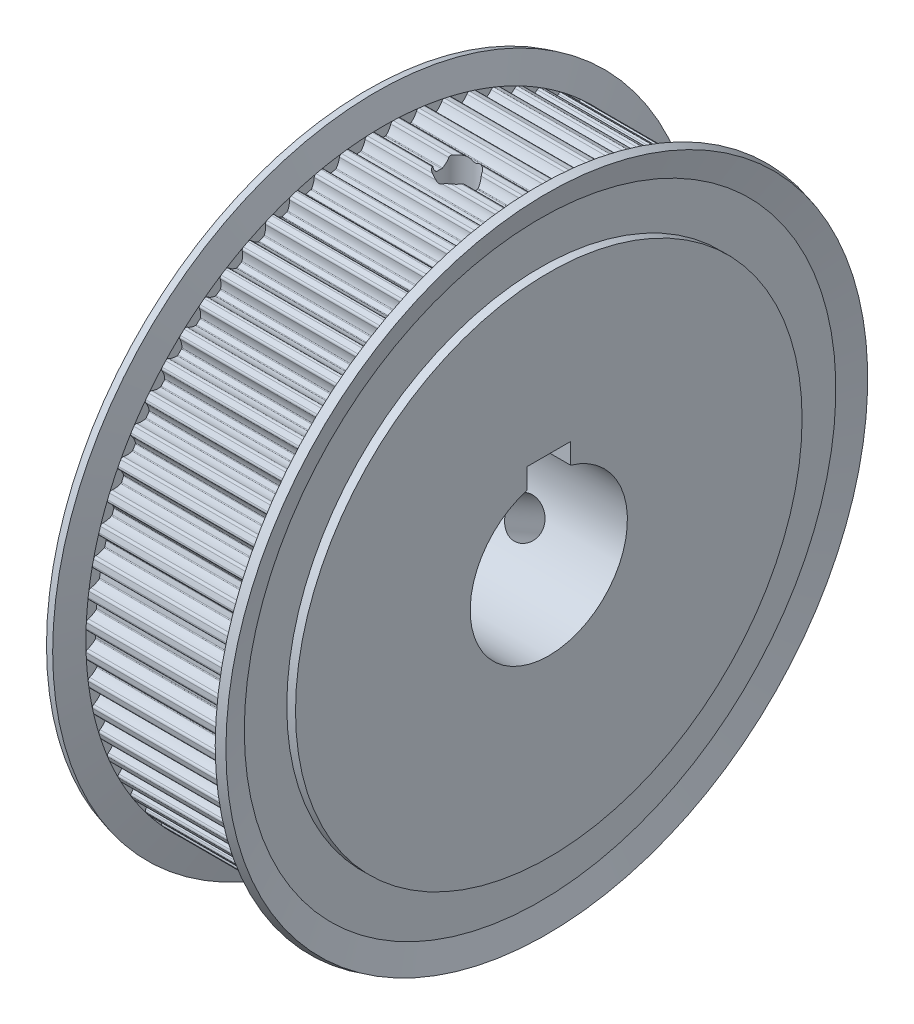
from build123d import *

# Parameters (mm, degrees)
SKETCH_2_W          = 21
SKETCH_2_H          = 9
SKETCH_3_R          = 38.995
CUT_EXTRUDE_1_DEPTH = 17
SKETCH_4_W          = 5
SKETCH_4_H          = 11
CUT_EXTRUDE_2_DEPTH = 21
SKETCH_5_W          = 2.067
SKETCH_5_H          = 33.995


with BuildPart() as part:
    # ｽｹｯﾁ1 → 回転1 (revolve)
    with BuildSketch(Plane.XY):
        Polygon((0, 0), (0, 29), (1, 29), (1, 33.863347502), (0.22888685, 36.741180955), (1.194812677, 37), (2, 33.995), (19, 33.995), (19.805187323, 37), (20.77111315, 36.741180955), (20, 33.863347502), (20, 29), (21, 29), (21, 0), align=None)
    revolve(axis=Axis((21, 0, 0), (-1, 0, 0)))

    # ｽｹｯﾁ2 → ｶｯﾄ - 回転1 (revolve, cut)
    with BuildSketch(Plane.XY):
        with Locations((10.5, 4.5)):
            Rectangle(SKETCH_2_W, SKETCH_2_H)
    revolve(axis=Axis((21, 0, 0), (-1, 0, 0)), mode=Mode.SUBTRACT)

    # ｽｹｯﾁ3 → ｶｯﾄ - 押し出し1 (cut)
    with BuildSketch(Plane(origin=(2, 0, 0), x_dir=(0, 0, -1), z_dir=(1, 0, 0))):
        Circle(SKETCH_3_R)
        with BuildLine():
            ThreePointArc((-33.777168623, -0.911681599), (-33.922614353, -1.016968917), (-33.974202204, -1.18895314))
            ThreePointArc((-33.974202204, -1.18895314), (-33.962644297, -1.482840979), (-33.948544212, -1.776617823))
            ThreePointArc((-33.948544212, -1.776617823), (-33.882163306, -1.943451535), (-33.728094586, -2.035661844))
            ThreePointArc((-33.728094586, -2.035661844), (-33.250950848, -2.205234651), (-32.83260935, -2.490561611))
            ThreePointArc((-32.83260935, -2.490561611), (-32.797994707, -2.535862252), (-32.782784237, -2.590807344))
            ThreePointArc((-32.782784237, -2.590807344), (-32.759862676, -2.866116264), (-32.73462912, -3.141222911))
            ThreePointArc((-32.73462912, -3.141222911), (-32.740067244, -3.197974916), (-32.766289768, -3.248598454))
            ThreePointArc((-32.766289768, -3.248598454), (-33.128729197, -3.60223486), (-33.569178012, -3.852086595))
            ThreePointArc((-33.569178012, -3.852086595), (-33.704893882, -3.969649693), (-33.741296014, -4.145475642))
            ThreePointArc((-33.741296014, -4.145475642), (-33.704168075, -4.43723781), (-33.664517306, -4.728667842))
            ThreePointArc((-33.664517306, -4.728667842), (-33.583848484, -4.889081224), (-33.422329383, -4.967512671))
            ThreePointArc((-33.422329383, -4.967512671), (-32.93222222, -5.094854328), (-32.490604858, -5.342634543))
            ThreePointArc((-32.490604858, -5.342634543), (-32.452173557, -5.384745989), (-32.432232107, -5.43815645))
            ThreePointArc((-32.432232107, -5.43815645), (-32.385402958, -5.710420323), (-32.336288235, -5.982281187))
            ThreePointArc((-32.336288235, -5.982281187), (-32.336759592, -6.039290865), (-32.358470133, -6.092006878))
            ThreePointArc((-32.358470133, -6.092006878), (-32.688708926, -6.475886269), (-33.105705687, -6.763174885))
            ThreePointArc((-33.105705687, -6.763174885), (-33.230658816, -6.892119033), (-33.251598189, -7.070448561))
            ThreePointArc((-33.251598189, -7.070448561), (-33.189182784, -7.357864578), (-33.124283096, -7.644729844))
            ThreePointArc((-33.124283096, -7.644729844), (-33.029940296, -7.797502053), (-32.862200073, -7.861557728))
            ThreePointArc((-32.862200073, -7.861557728), (-32.362859356, -7.945699158), (-31.901327011, -8.154047007))
            ThreePointArc((-31.901327011, -8.154047007), (-31.859371701, -8.192648697), (-31.834851107, -8.244117901))
            ThreePointArc((-31.834851107, -8.244117901), (-31.764470885, -8.511263973), (-31.691848915, -8.77780937))
            ThreePointArc((-31.691848915, -8.77780937), (-31.68734954, -8.834643506), (-31.704383001, -8.889051453))
            ThreePointArc((-31.704383001, -8.889051453), (-31.999907843, -9.300252273), (-32.390278951, -9.622791331))
            ThreePointArc((-32.390278951, -9.622791331), (-32.503518375, -9.762135195), (-32.508835621, -9.941611117))
            ThreePointArc((-32.508835621, -9.941611117), (-32.421607769, -10.222493564), (-32.331953091, -10.502610835))
            ThreePointArc((-32.331953091, -10.502610835), (-32.224654318, -10.646579182), (-32.051969577, -10.695771583))
            ThreePointArc((-32.051969577, -10.695771583), (-31.547195595, -10.736072418), (-31.069260809, -10.903402246))
            ThreePointArc((-31.069260809, -10.903402246), (-31.024100792, -10.938200398), (-30.995187669, -10.987336637))
            ThreePointArc((-30.995187669, -10.987336637), (-30.90179195, -11.247332096), (-30.806215367, -11.506533786))
            ThreePointArc((-30.806215367, -11.506533786), (-30.796779693, -11.56275958), (-30.80900643, -11.618445115))
            ThreePointArc((-30.80900643, -11.618445115), (-31.067568184, -12.0538378), (-31.428342635, -12.409172525))
            ThreePointArc((-31.428342635, -12.409172525), (-31.529006529, -12.557855605), (-31.518661189, -12.73711199))
            ThreePointArc((-31.518661189, -12.73711199), (-31.407284746, -13.009323191), (-31.2935574, -13.280560616))
            ThreePointArc((-31.2935574, -13.280560616), (-31.174119263, -13.414629416), (-30.99780424, -13.448584158))
            ThreePointArc((-30.99780424, -13.448584158), (-30.491438626, -13.444737685), (-30.000738771, -13.569776011))
            ThreePointArc((-30.000738771, -13.569776011), (-29.952717742, -13.600505791), (-29.919632137, -13.646935107))
            ThreePointArc((-29.919632137, -13.646935107), (-29.803931719, -13.897801232), (-29.686127918, -14.147686533))
            ThreePointArc((-29.686127918, -14.147686533), (-29.67182775, -14.202875997), (-29.679154645, -14.259415261))
            ThreePointArc((-29.679154645, -14.259415261), (-29.89878552, -14.715686288), (-30.227217655, -15.101112423))
            ThreePointArc((-30.227217655, -15.101112423), (-30.314539909, -15.25800316), (-30.288610707, -15.435675769))
            ThreePointArc((-30.288610707, -15.435675769), (-30.153933318, -15.697144023), (-30.016998841, -15.957437311))
            ThreePointArc((-30.016998841, -15.957437311), (-29.886330337, -16.08058622), (-29.707726895, -16.099044887))
            ThreePointArc((-29.707726895, -16.099044887), (-29.203623396, -16.05108038), (-28.703892992, -16.132875587))
            ThreePointArc((-28.703892992, -16.132875587), (-28.653376423, -16.159303124), (-28.616370138, -16.20267216))
            ThreePointArc((-28.616370138, -16.20267216), (-28.479245572, -16.442499708), (-28.340111111, -16.681166842))
            ThreePointArc((-28.340111111, -16.681166842), (-28.32105529, -16.734899884), (-28.323426541, -16.791862514))
            ThreePointArc((-28.323426541, -16.791862514), (-28.502455004, -17.265539439), (-28.796045267, -17.678123706))
            ThreePointArc((-28.796045267, -17.678123706), (-28.869361332, -17.842028072), (-28.828045612, -18.016764725))
            ThreePointArc((-28.828045612, -18.016764725), (-28.671092251, -18.265500106), (-28.511992797, -18.512868274))
            ThreePointArc((-28.511992797, -18.512868274), (-28.371088391, -18.624160053), (-28.191555811, -18.626982163))
            ThreePointArc((-28.191555811, -18.626982163), (-27.693550959, -18.535264661), (-27.188593259, -18.573194239))
            ThreePointArc((-27.188593259, -18.573194239), (-27.135965609, -18.595118401), (-27.095320283, -18.635097095))
            ThreePointArc((-27.095320283, -18.635097095), (-26.93781517, -18.862060833), (-26.778408946, -19.0876934))
            ThreePointArc((-26.778408946, -19.0876934), (-26.754742496, -19.139561146), (-26.752140102, -19.196513683))
            ThreePointArc((-26.752140102, -19.196513683), (-26.889203644, -19.683991484), (-27.14571762, -20.120593821))
            ThreePointArc((-27.14571762, -20.120593821), (-27.204469487, -20.290264398), (-27.148081684, -20.460735223))
            ThreePointArc((-27.148081684, -20.460735223), (-26.970046861, -20.694844704), (-26.789993272, -20.92740513))
            ThreePointArc((-26.789993272, -20.92740513), (-26.639925332, -21.025992783), (-26.460829964, -21.013156858))
            ThreePointArc((-26.460829964, -21.013156858), (-25.97271388, -20.878384387), (-25.466371917, -20.872159667))
            ThreePointArc((-25.466371917, -20.872159667), (-25.412033713, -20.889413599), (-25.368058681, -20.925697689))
            ThreePointArc((-25.368058681, -20.925697689), (-25.191371729, -21.138070286), (-25.01290692, -21.348951085))
            ThreePointArc((-25.01290692, -21.348951085), (-24.984809955, -21.398558794), (-24.977253724, -21.455067799))
            ThreePointArc((-24.977253724, -21.455067799), (-25.071309207, -21.952636467), (-25.288794664, -22.409934061))
            ThreePointArc((-25.288794664, -22.409934061), (-25.332535204, -22.584079556), (-25.261504461, -22.748987172))
            ThreePointArc((-25.261504461, -22.748987172), (-25.063743129, -22.966689038), (-24.864105721, -23.182671798))
            ThreePointArc((-24.864105721, -23.182671798), (-24.706016355, -23.267805011), (-24.528721224, -23.239408742))
            ThreePointArc((-24.528721224, -23.239408742), (-24.054208764, -23.062607), (-23.550336105, -23.012275357))
            ThreePointArc((-23.550336105, -23.012275357), (-23.494700895, -23.024727746), (-23.447730834, -23.057041088))
            ThreePointArc((-23.447730834, -23.057041088), (-23.253206738, -23.253206261), (-23.057041569, -23.447730362))
            ThreePointArc((-23.057041569, -23.447730362), (-23.024727926, -23.494700483), (-23.012275364, -23.55033588))
            ThreePointArc((-23.012275364, -23.55033588), (-23.062606969, -24.054208629), (-23.239408718, -24.528721178))
            ThreePointArc((-23.239408718, -24.528721178), (-23.267805032, -24.706016236), (-23.182671936, -24.864105592))
            ThreePointArc((-23.182671936, -24.864105592), (-22.966689178, -25.063743001), (-22.748987313, -25.261504334))
            ThreePointArc((-22.748987313, -25.261504334), (-22.584079676, -25.332535194), (-22.409934104, -25.288794692))
            ThreePointArc((-22.409934104, -25.288794692), (-21.952636596, -25.071309249), (-21.455068018, -24.977253737))
            ThreePointArc((-21.455068018, -24.977253737), (-21.398559218, -24.984809812), (-21.348951598, -25.012906482))
            ThreePointArc((-21.348951598, -25.012906482), (-21.138070545, -25.191371512), (-20.925697689, -25.368058681))
            ThreePointArc((-20.925697689, -25.368058681), (-20.889413652, -25.412033614), (-20.872159693, -25.466371694))
            ThreePointArc((-20.872159693, -25.466371694), (-20.878384368, -25.972713748), (-21.013156842, -26.460829925))
            ThreePointArc((-21.013156842, -26.460829925), (-21.025992812, -26.63992522), (-20.92740528, -26.789993155))
            ThreePointArc((-20.92740528, -26.789993155), (-20.694844855, -26.970046745), (-20.460735375, -27.14808157))
            ThreePointArc((-20.460735375, -27.14808157), (-20.290264514, -27.204469488), (-20.120593854, -27.145717645))
            ThreePointArc((-20.120593854, -27.145717645), (-19.683991605, -26.889203695), (-19.196513902, -26.752140134))
            ThreePointArc((-19.196513902, -26.752140134), (-19.139561581, -26.75474239), (-19.087693949, -26.778408555))
            ThreePointArc((-19.087693949, -26.778408555), (-18.862061109, -26.937814976), (-18.635097095, -27.095320283))
            ThreePointArc((-18.635097095, -27.095320283), (-18.59511846, -27.135965519), (-18.573194282, -27.188593049))
            ThreePointArc((-18.573194282, -27.188593049), (-18.535264654, -27.693550822), (-18.626982145, -28.191555754))
            ThreePointArc((-18.626982145, -28.191555754), (-18.624160093, -28.371088278), (-18.512868425, -28.511992699))
            ThreePointArc((-18.512868425, -28.511992699), (-18.265500262, -28.671092152), (-18.016764886, -28.828045512))
            ThreePointArc((-18.016764886, -28.828045512), (-17.842028188, -28.869361343), (-17.678123736, -28.796045296))
            ThreePointArc((-17.678123736, -28.796045296), (-17.26553942, -28.502454994), (-16.791862432, -28.323426522))
            ThreePointArc((-16.791862432, -28.323426522), (-16.734900176, -28.321055246), (-16.681167424, -28.340110769))
            ThreePointArc((-16.681167424, -28.340110769), (-16.4425, -28.479245403), (-16.20267216, -28.616370138))
            ThreePointArc((-16.20267216, -28.616370138), (-16.159303151, -28.653376389), (-16.132875613, -28.703892908))
            ThreePointArc((-16.132875613, -28.703892908), (-16.051080382, -29.203623322), (-16.099044874, -29.707726837))
            ThreePointArc((-16.099044874, -29.707726837), (-16.080586272, -29.886330223), (-15.957437479, -30.016998752))
            ThreePointArc((-15.957437479, -30.016998752), (-15.697144191, -30.15393323), (-15.435675938, -30.288610621))
            ThreePointArc((-15.435675938, -30.288610621), (-15.258003253, -30.314539926), (-15.101112423, -30.227217655))
            ThreePointArc((-15.101112423, -30.227217655), (-14.715686195, -29.89878546), (-14.25941505, -29.679154575))
            ThreePointArc((-14.25941505, -29.679154575), (-14.202876223, -29.671827735), (-14.147687142, -29.686127628))
            ThreePointArc((-14.147687142, -29.686127628), (-13.897801537, -29.803931577), (-13.646935107, -29.919632137))
            ThreePointArc((-13.646935107, -29.919632137), (-13.600505865, -29.952717665), (-13.56977609, -30.000738572))
            ThreePointArc((-13.56977609, -30.000738572), (-13.444737702, -30.491438487), (-13.448584149, -30.997804174))
            ThreePointArc((-13.448584149, -30.997804174), (-13.41462948, -31.174119151), (-13.280560791, -31.293557326))
            ThreePointArc((-13.280560791, -31.293557326), (-13.009323371, -31.407284671), (-12.737112175, -31.518661114))
            ThreePointArc((-12.737112175, -31.518661114), (-12.557855701, -31.529006556), (-12.409172525, -31.428342635))
            ThreePointArc((-12.409172525, -31.428342635), (-12.053837714, -31.067568116), (-11.618444913, -30.809006343))
            ThreePointArc((-11.618444913, -30.809006343), (-11.562759807, -30.796779699), (-11.506534418, -30.806215131))
            ThreePointArc((-11.506534418, -30.806215131), (-11.247332413, -30.901791835), (-10.987336637, -30.995187669))
            ThreePointArc((-10.987336637, -30.995187669), (-10.938200432, -31.024100762), (-10.903402286, -31.069260728))
            ThreePointArc((-10.903402286, -31.069260728), (-10.736072434, -31.547195518), (-10.695771579, -32.051969511))
            ThreePointArc((-10.695771579, -32.051969511), (-10.646579255, -32.224654212), (-10.502611015, -32.331953032))
            ThreePointArc((-10.502611015, -32.331953032), (-10.222493745, -32.421607712), (-9.941611298, -32.508835565))
            ThreePointArc((-9.941611298, -32.508835565), (-9.762135284, -32.503518408), (-9.622791331, -32.390278951))
            ThreePointArc((-9.622791331, -32.390278951), (-9.300252247, -31.999907819), (-8.889051391, -31.704382968))
            ThreePointArc((-8.889051391, -31.704382968), (-8.834643807, -31.687349574), (-8.77781002, -31.691848735))
            ThreePointArc((-8.77781002, -31.691848735), (-8.511264298, -31.764470798), (-8.244117901, -31.834851107))
            ThreePointArc((-8.244117901, -31.834851107), (-8.192648733, -31.859371675), (-8.154047054, -31.901326935))
            ThreePointArc((-8.154047054, -31.901326935), (-7.94569918, -32.362859285), (-7.86155773, -32.862200013))
            ThreePointArc((-7.86155773, -32.862200013), (-7.797502014, -33.029940342), (-7.644729668, -33.124283136))
            ThreePointArc((-7.644729668, -33.124283136), (-7.357864588, -33.189182781), (-7.070448756, -33.251598148))
            ThreePointArc((-7.070448756, -33.251598148), (-6.892119123, -33.230658859), (-6.763174885, -33.105705687))
            ThreePointArc((-6.763174885, -33.105705687), (-6.475886248, -32.688708903), (-6.092006826, -32.358470099))
            ThreePointArc((-6.092006826, -32.358470099), (-6.039290835, -32.336759585), (-5.982281187, -32.336288235))
            ThreePointArc((-5.982281187, -32.336288235), (-5.710420323, -32.385402958), (-5.43815645, -32.432232107))
            ThreePointArc((-5.43815645, -32.432232107), (-5.384746029, -32.452173533), (-5.342634599, -32.490604782))
            ThreePointArc((-5.342634599, -32.490604782), (-5.094854358, -32.932222145), (-4.96751268, -33.422329317))
            ThreePointArc((-4.96751268, -33.422329317), (-4.889081184, -33.583848524), (-4.728667664, -33.664517331))
            ThreePointArc((-4.728667664, -33.664517331), (-4.437237815, -33.704168074), (-4.14547583, -33.741295991))
            ThreePointArc((-4.14547583, -33.741295991), (-3.969649775, -33.70489393), (-3.852086595, -33.569178012))
            ThreePointArc((-3.852086595, -33.569178012), (-3.602234844, -33.128729175), (-3.24859841, -32.766289734))
            ThreePointArc((-3.24859841, -32.766289734), (-3.197975213, -32.740067332), (-3.141223582, -32.734629056))
            ThreePointArc((-3.141223582, -32.734629056), (-2.866116936, -32.759862617), (-2.590808017, -32.782784183))
            ThreePointArc((-2.590808017, -32.782784183), (-2.535862458, -32.797994605), (-2.490561468, -32.832609511))
            ThreePointArc((-2.490561468, -32.832609511), (-2.205234616, -33.250950918), (-2.035661857, -33.728094528))
            ThreePointArc((-2.035661857, -33.728094528), (-1.943451489, -33.882163345), (-1.776617644, -33.948544221))
            ThreePointArc((-1.776617644, -33.948544221), (-1.482840984, -33.962644297), (-1.18895333, -33.974202198))
            ThreePointArc((-1.18895333, -33.974202198), (-1.016968994, -33.922614408), (-0.911681599, -33.777168623))
            ThreePointArc((-0.911681599, -33.777168623), (-0.701168253, -33.316619809), (-0.380466189, -32.924738112))
            ThreePointArc((-0.380466189, -32.924738112), (-0.332321063, -32.894203395), (-0.276259369, -32.883839584))
            ThreePointArc((-0.276259369, -32.883839584), (-3.37e-07, -32.885), (0.276258695, -32.883839589))
            ThreePointArc((0.276258695, -32.883839589), (0.332320839, -32.894203307), (0.38046633, -32.924738245))
            ThreePointArc((0.38046633, -32.924738245), (0.701168287, -33.316619863), (0.911681579, -33.77716856))
            ThreePointArc((0.911681579, -33.77716856), (1.016969036, -33.922614437), (1.188953498, -33.974202192))
            ThreePointArc((1.188953498, -33.974202192), (1.482841158, -33.962644289), (1.776617823, -33.948544212))
            ThreePointArc((1.776617823, -33.948544212), (1.943451535, -33.882163306), (2.035661844, -33.728094586))
            ThreePointArc((2.035661844, -33.728094586), (2.205234649, -33.250950852), (2.490561605, -32.832609357))
            ThreePointArc((2.490561605, -32.832609357), (2.535862248, -32.797994709), (2.590807344, -32.782784237))
            ThreePointArc((2.590807344, -32.782784237), (2.866116264, -32.759862676), (3.141222911, -32.73462912))
            ThreePointArc((3.141222911, -32.73462912), (3.197974975, -32.740067262), (3.24859855, -32.766289845))
            ThreePointArc((3.24859855, -32.766289845), (3.602234875, -33.128729217), (3.852086567, -33.569177944))
            ThreePointArc((3.852086567, -33.569177944), (3.969649816, -33.704893955), (4.145475998, -33.74129597))
            ThreePointArc((4.145475998, -33.74129597), (4.437237988, -33.704168051), (4.728667842, -33.664517306))
            ThreePointArc((4.728667842, -33.664517306), (4.889081224, -33.583848484), (4.967512671, -33.422329383))
            ThreePointArc((4.967512671, -33.422329383), (5.09485433, -32.932222216), (5.342634548, -32.490604851))
            ThreePointArc((5.342634548, -32.490604851), (5.384745993, -32.452173555), (5.43815645, -32.432232107))
            ThreePointArc((5.43815645, -32.432232107), (5.710419991, -32.385403016), (5.982280524, -32.336288357))
            ThreePointArc((5.982280524, -32.336288357), (6.039290596, -32.336759537), (6.092006982, -32.358470201))
            ThreePointArc((6.092006982, -32.358470201), (6.475886286, -32.688708945), (6.763174852, -33.105705622))
            ThreePointArc((6.763174852, -33.105705622), (6.892119167, -33.230658879), (7.070448921, -33.251598113))
            ThreePointArc((7.070448921, -33.251598113), (7.357864758, -33.189182744), (7.644729844, -33.124283096))
            ThreePointArc((7.644729844, -33.124283096), (7.797502053, -33.029940296), (7.861557728, -32.862200073))
            ThreePointArc((7.861557728, -32.862200073), (7.945699158, -32.362859355), (8.154047009, -31.901327008))
            ThreePointArc((8.154047009, -31.901327008), (8.192648698, -31.8593717), (8.244117901, -31.834851107))
            ThreePointArc((8.244117901, -31.834851107), (8.511263973, -31.764470885), (8.77780937, -31.691848915))
            ThreePointArc((8.77780937, -31.691848915), (8.834643567, -31.687349547), (8.88905156, -31.704383059))
            ThreePointArc((8.88905156, -31.704383059), (9.300252291, -31.999907859), (9.622791292, -32.390278889))
            ThreePointArc((9.622791292, -32.390278889), (9.762135329, -32.503518424), (9.94161146, -32.508835516))
            ThreePointArc((9.94161146, -32.508835516), (10.222493735, -32.421607715), (10.502610835, -32.331953091))
            ThreePointArc((10.502610835, -32.331953091), (10.646579182, -32.224654318), (10.695771583, -32.051969577))
            ThreePointArc((10.695771583, -32.051969577), (10.736072419, -31.547195592), (10.903402248, -31.069260804))
            ThreePointArc((10.903402248, -31.069260804), (10.938200401, -31.02410079), (10.987336637, -30.995187669))
            ThreePointArc((10.987336637, -30.995187669), (11.247332096, -30.90179195), (11.506533786, -30.806215367))
            ThreePointArc((11.506533786, -30.806215367), (11.562759565, -30.796779693), (11.618445087, -30.809006418))
            ThreePointArc((11.618445087, -30.809006418), (12.053837759, -31.067568152), (12.409172481, -31.428342577))
            ThreePointArc((12.409172481, -31.428342577), (12.557855584, -31.529006524), (12.737112019, -31.518661177))
            ThreePointArc((12.737112019, -31.518661177), (13.009323205, -31.40728474), (13.280560616, -31.2935574))
            ThreePointArc((13.280560616, -31.2935574), (13.414629416, -31.174119263), (13.448584158, -30.99780424))
            ThreePointArc((13.448584158, -30.99780424), (13.444737685, -30.491438623), (13.569776013, -30.000738765))
            ThreePointArc((13.569776013, -30.000738765), (13.600505793, -29.95271774), (13.646935107, -29.919632137))
            ThreePointArc((13.646935107, -29.919632137), (13.897801232, -29.803931719), (14.147686533, -29.686127918))
            ThreePointArc((14.147686533, -29.686127918), (14.202875984, -29.67182775), (14.259415236, -29.679154636))
            ThreePointArc((14.259415236, -29.679154636), (14.715686242, -29.89878549), (15.101112366, -30.227217592))
            ThreePointArc((15.101112366, -30.227217592), (15.258003129, -30.314539903), (15.435675788, -30.288610697))
            ThreePointArc((15.435675788, -30.288610697), (15.697144032, -30.153933313), (15.957437311, -30.016998841))
            ThreePointArc((15.957437311, -30.016998841), (16.08058622, -29.886330337), (16.099044887, -29.707726895))
            ThreePointArc((16.099044887, -29.707726895), (16.05108038, -29.203623391), (16.13287559, -28.703892984))
            ThreePointArc((16.13287559, -28.703892984), (16.159303126, -28.653376419), (16.20267216, -28.616370138))
            ThreePointArc((16.20267216, -28.616370138), (16.442499708, -28.479245572), (16.681166842, -28.340111111))
            ThreePointArc((16.681166842, -28.340111111), (16.734899937, -28.321055282), (16.791862618, -28.323426566))
            ThreePointArc((16.791862618, -28.323426566), (17.265539467, -28.502455019), (17.678123675, -28.796045239))
            ThreePointArc((17.678123675, -28.796045239), (17.842028062, -28.869361331), (18.016764743, -28.828045601))
            ThreePointArc((18.016764743, -28.828045601), (18.265500115, -28.671092246), (18.512868274, -28.511992797))
            ThreePointArc((18.512868274, -28.511992797), (18.624160053, -28.371088391), (18.626982163, -28.191555811))
            ThreePointArc((18.626982163, -28.191555811), (18.535264653, -27.693550814), (18.573194298, -27.188592973))
            ThreePointArc((18.573194298, -27.188592973), (18.595118482, -27.135965487), (18.635097095, -27.095320283))
            ThreePointArc((18.635097095, -27.095320283), (18.862060833, -26.93781517), (19.0876934, -26.778408946))
            ThreePointArc((19.0876934, -26.778408946), (19.139561162, -26.754742492), (19.196513716, -26.752140107))
            ThreePointArc((19.196513716, -26.752140107), (19.683991477, -26.88920364), (20.120593782, -27.145717589))
            ThreePointArc((20.120593782, -27.145717589), (20.290264553, -27.204469489), (20.46073551, -27.148081468))
            ThreePointArc((20.46073551, -27.148081468), (20.694844846, -26.970046752), (20.92740513, -26.789993272))
            ThreePointArc((20.92740513, -26.789993272), (21.025992783, -26.639925332), (21.013156858, -26.460829964))
            ThreePointArc((21.013156858, -26.460829964), (20.878384366, -25.972713733), (20.872159701, -25.466371621))
            ThreePointArc((20.872159701, -25.466371621), (20.88941367, -25.412033582), (20.925697689, -25.368058681))
            ThreePointArc((20.925697689, -25.368058681), (21.138070286, -25.191371729), (21.348951085, -25.01290692))
            ThreePointArc((21.348951085, -25.01290692), (21.398558834, -24.984809941), (21.455067884, -24.977253729))
            ThreePointArc((21.455067884, -24.977253729), (21.952636488, -25.071309214), (22.409934027, -25.288794643))
            ThreePointArc((22.409934027, -25.288794643), (22.584079714, -25.332535191), (22.748987438, -25.261504221))
            ThreePointArc((22.748987438, -25.261504221), (22.96668917, -25.063743008), (23.182671798, -24.864105721))
            ThreePointArc((23.182671798, -24.864105721), (23.267805011, -24.706016355), (23.239408742, -24.528721224))
            ThreePointArc((23.239408742, -24.528721224), (23.062606966, -24.054208617), (23.012275366, -23.550335804))
            ThreePointArc((23.012275366, -23.550335804), (23.024727806, -23.494700757), (23.057041088, -23.447730834))
            ThreePointArc((23.057041088, -23.447730834), (23.253206261, -23.253206738), (23.447730362, -23.057041569))
            ThreePointArc((23.447730362, -23.057041569), (23.494700505, -23.024727916), (23.55033593, -23.012275362))
            ThreePointArc((23.55033593, -23.012275362), (24.054208634, -23.06260697), (24.528721142, -23.239408699))
            ThreePointArc((24.528721142, -23.239408699), (24.706016384, -23.267805006), (24.864105824, -23.182671687))
            ThreePointArc((24.864105824, -23.182671687), (25.063743116, -22.966689052), (25.261504334, -22.748987313))
            ThreePointArc((25.261504334, -22.748987313), (25.332535194, -22.584079676), (25.288794692, -22.409934104))
            ThreePointArc((25.288794692, -22.409934104), (25.071309202, -21.952636451), (24.97725372, -21.455067715))
            ThreePointArc((24.97725372, -21.455067715), (24.984809861, -21.398559074), (25.012906482, -21.348951598))
            ThreePointArc((25.012906482, -21.348951598), (25.191371295, -21.138070803), (25.368058252, -20.925698209))
            ThreePointArc((25.368058252, -20.925698209), (25.41203333, -20.889413807), (25.466371722, -20.872159689))
            ThreePointArc((25.466371722, -20.872159689), (25.972713741, -20.878384367), (26.460829886, -21.013156826))
            ThreePointArc((26.460829886, -21.013156826), (26.639925218, -21.025992812), (26.789993179, -20.927405249))
            ThreePointArc((26.789993179, -20.927405249), (26.970046757, -20.694844839), (27.14808157, -20.460735375))
            ThreePointArc((27.14808157, -20.460735375), (27.204469488, -20.290264514), (27.145717645, -20.120593854))
            ThreePointArc((27.145717645, -20.120593854), (26.889203638, -19.68399147), (26.752140092, -19.196513611))
            ThreePointArc((26.752140092, -19.196513611), (26.754742425, -19.139561438), (26.778408555, -19.087693949))
            ThreePointArc((26.778408555, -19.087693949), (26.937814783, -18.862061386), (27.095319901, -18.635097651))
            ThreePointArc((27.095319901, -18.635097651), (27.135965247, -18.595118641), (27.188593069, -18.573194278))
            ThreePointArc((27.188593069, -18.573194278), (27.69355082, -18.535264654), (28.19155573, -18.626982138))
            ThreePointArc((28.19155573, -18.626982138), (28.371088423, -18.624160042), (28.511992879, -18.512868147))
            ThreePointArc((28.511992879, -18.512868147), (28.671092241, -18.265500122), (28.828045512, -18.016764886))
            ThreePointArc((28.828045512, -18.016764886), (28.869361343, -17.842028188), (28.796045296, -17.678123736))
            ThreePointArc((28.796045296, -17.678123736), (28.502454996, -17.265539424), (28.323426524, -16.791862441))
            ThreePointArc((28.323426524, -16.791862441), (28.321055246, -16.73490018), (28.340110769, -16.681167424))
            ThreePointArc((28.340110769, -16.681167424), (28.479245235, -16.442500292), (28.616369806, -16.202672747))
            ThreePointArc((28.616369806, -16.202672747), (28.653376086, -16.159303392), (28.703892812, -16.132875641))
            ThreePointArc((28.703892812, -16.132875641), (29.20362326, -16.051080385), (29.707726813, -16.099044868))
            ThreePointArc((29.707726813, -16.099044868), (29.886330236, -16.080586266), (30.016998777, -15.957437433))
            ThreePointArc((30.016998777, -15.957437433), (30.153933242, -15.697144168), (30.288610621, -15.435675938))
            ThreePointArc((30.288610621, -15.435675938), (30.314539926, -15.258003253), (30.227217655, -15.101112423))
            ThreePointArc((30.227217655, -15.101112423), (29.898785463, -14.715686199), (29.679154578, -14.259415059))
            ThreePointArc((29.679154578, -14.259415059), (29.671827735, -14.202876227), (29.686127628, -14.147687142))
            ThreePointArc((29.686127628, -14.147687142), (29.803931434, -13.897801843), (29.919631857, -13.64693572))
            ThreePointArc((29.919631857, -13.64693572), (29.952717427, -13.600506091), (30.00073859, -13.569776083))
            ThreePointArc((30.00073859, -13.569776083), (30.491438487, -13.444737702), (30.997804156, -13.448584146))
            ThreePointArc((30.997804156, -13.448584146), (31.174119161, -13.414629474), (31.293557341, -13.280560755))
            ThreePointArc((31.293557341, -13.280560755), (31.407284679, -13.009323353), (31.518661114, -12.737112175))
            ThreePointArc((31.518661114, -12.737112175), (31.529006556, -12.557855701), (31.428342635, -12.409172525))
            ThreePointArc((31.428342635, -12.409172525), (31.06756812, -12.053837719), (30.809006348, -11.618444924))
            ThreePointArc((30.809006348, -11.618444924), (30.796779699, -11.562759814), (30.806215131, -11.506534418))
            ThreePointArc((30.806215131, -11.506534418), (30.901791719, -11.24733273), (30.995187444, -10.987337272))
            ThreePointArc((30.995187444, -10.987337272), (31.024100504, -10.938200725), (31.069260634, -10.903402334))
            ThreePointArc((31.069260634, -10.903402334), (31.547195458, -10.736072447), (32.051969493, -10.695771578))
            ThreePointArc((32.051969493, -10.695771578), (32.224654221, -10.646579249), (32.331953044, -10.502610978))
            ThreePointArc((32.331953044, -10.502610978), (32.421607718, -10.222493726), (32.508835565, -9.941611298))
            ThreePointArc((32.508835565, -9.941611298), (32.503518408, -9.762135284), (32.390278951, -9.622791331))
            ThreePointArc((32.390278951, -9.622791331), (31.999907821, -9.30025225), (31.704382971, -8.889051397))
            ThreePointArc((31.704382971, -8.889051397), (31.687349574, -8.83464381), (31.691848735, -8.77781002))
            ThreePointArc((31.691848735, -8.77781002), (31.76447071, -8.511264624), (31.834850938, -8.244118554))
            ThreePointArc((31.834850938, -8.244118554), (31.859371444, -8.192649045), (31.901326848, -8.154047107))
            ThreePointArc((31.901326848, -8.154047107), (32.362859224, -7.945699198), (32.862199989, -7.861557731))
            ThreePointArc((32.862199989, -7.861557731), (33.029940316, -7.797502036), (33.124283127, -7.644729709))
            ThreePointArc((33.124283127, -7.644729709), (33.189182777, -7.357864609), (33.251598148, -7.070448756))
            ThreePointArc((33.251598148, -7.070448756), (33.230658859, -6.892119123), (33.105705687, -6.763174885))
            ThreePointArc((33.105705687, -6.763174885), (32.688708904, -6.475886249), (32.3584701, -6.092006829))
            ThreePointArc((32.3584701, -6.092006829), (32.336759586, -6.039290836), (32.336288235, -5.982281187))
            ThreePointArc((32.336288235, -5.982281187), (32.385402899, -5.710420655), (32.432231995, -5.438157115))
            ThreePointArc((32.432231995, -5.438157115), (32.45217333, -5.384746361), (32.490604699, -5.342634661))
            ThreePointArc((32.490604699, -5.342634661), (32.932222089, -5.094854381), (33.4223293, -4.967512682))
            ThreePointArc((33.4223293, -4.967512682), (33.583848503, -4.889081205), (33.664517325, -4.728667706))
            ThreePointArc((33.664517325, -4.728667706), (33.704168071, -4.437237836), (33.741295991, -4.14547583))
            ThreePointArc((33.741295991, -4.14547583), (33.70489393, -3.969649775), (33.569178012, -3.852086595))
            ThreePointArc((33.569178012, -3.852086595), (33.128729175, -3.602234844), (32.766289734, -3.24859841))
            ThreePointArc((32.766289734, -3.24859841), (32.740067332, -3.197975213), (32.734629056, -3.141223582))
            ThreePointArc((32.734629056, -3.141223582), (32.759862647, -2.8661166), (32.782784237, -2.590807344))
            ThreePointArc((32.782784237, -2.590807344), (32.79799473, -2.535862207), (32.832609426, -2.490561543))
            ThreePointArc((32.832609426, -2.490561543), (33.250950856, -2.205234647), (33.728094503, -2.035661862))
            ThreePointArc((33.728094503, -2.035661862), (33.882163324, -1.943451514), (33.948544219, -1.776617686))
            ThreePointArc((33.948544219, -1.776617686), (33.962644296, -1.482841005), (33.974202198, -1.18895333))
            ThreePointArc((33.974202198, -1.18895333), (33.922614408, -1.016968994), (33.777168623, -0.911681599))
            ThreePointArc((33.777168623, -0.911681599), (33.316619811, -0.701168254), (32.924738115, -0.380466191))
            ThreePointArc((32.924738115, -0.380466191), (32.894203395, -0.332321065), (32.883839584, -0.276259369))
            ThreePointArc((32.883839584, -0.276259369), (32.885, 0), (32.883839584, 0.276259369))
            ThreePointArc((32.883839584, 0.276259369), (32.894203415, 0.332321115), (32.924738188, 0.380466269))
            ThreePointArc((32.924738188, 0.380466269), (33.31661982, 0.70116826), (33.777168543, 0.911681574))
            ThreePointArc((33.777168543, 0.911681574), (33.922614419, 1.01696901), (33.974202194, 1.188953453))
            ThreePointArc((33.974202194, 1.188953453), (33.96264429, 1.482841135), (33.948544212, 1.776617823))
            ThreePointArc((33.948544212, 1.776617823), (33.882163306, 1.943451535), (33.728094586, 2.035661844))
            ThreePointArc((33.728094586, 2.035661844), (33.250950854, 2.205234648), (32.832609359, 2.490561603))
            ThreePointArc((32.832609359, 2.490561603), (32.79799471, 2.535862246), (32.782784237, 2.590807344))
            ThreePointArc((32.782784237, 2.590807344), (32.759862647, 2.8661166), (32.734629056, 3.141223582))
            ThreePointArc((32.734629056, 3.141223582), (32.740067348, 3.197975269), (32.766289807, 3.248598502))
            ThreePointArc((32.766289807, 3.248598502), (33.128729188, 3.602234854), (33.569177934, 3.852086563))
            ThreePointArc((33.569177934, 3.852086563), (33.704893936, 3.969649784), (33.741295978, 4.145475936))
            ThreePointArc((33.741295978, 4.145475936), (33.704168055, 4.437237957), (33.664517306, 4.728667842))
            ThreePointArc((33.664517306, 4.728667842), (33.583848484, 4.889081224), (33.422329383, 4.967512671))
            ThreePointArc((33.422329383, 4.967512671), (32.932222082, 5.094854384), (32.490604619, 5.342634721))
            ThreePointArc((32.490604619, 5.342634721), (32.452173479, 5.384746116), (32.432232107, 5.43815645))
            ThreePointArc((32.432232107, 5.43815645), (32.385402958, 5.710420323), (32.336288235, 5.982281187))
            ThreePointArc((32.336288235, 5.982281187), (32.336759597, 6.039290894), (32.358470165, 6.092006927))
            ThreePointArc((32.358470165, 6.092006927), (32.688708917, 6.47588626), (33.105705612, 6.763174847))
            ThreePointArc((33.105705612, 6.763174847), (33.230658863, 6.892119134), (33.251598126, 7.070448861))
            ThreePointArc((33.251598126, 7.070448861), (33.189182751, 7.357864728), (33.124283096, 7.644729844))
            ThreePointArc((33.124283096, 7.644729844), (33.029940296, 7.797502053), (32.862200073, 7.861557728))
            ThreePointArc((32.862200073, 7.861557728), (32.362859215, 7.945699201), (31.90132676, 8.154047162))
            ThreePointArc((31.90132676, 8.154047162), (31.859371614, 8.192648816), (31.834851107, 8.244117901))
            ThreePointArc((31.834851107, 8.244117901), (31.764470798, 8.511264298), (31.691848735, 8.77781002))
            ThreePointArc((31.691848735, 8.77781002), (31.687349579, 8.834643857), (31.704383016, 8.88905148))
            ThreePointArc((31.704383016, 8.88905148), (31.999907828, 9.300252258), (32.390278889, 9.622791292))
            ThreePointArc((32.390278889, 9.622791292), (32.50351841, 9.762135291), (32.50883554, 9.941611381))
            ThreePointArc((32.50883554, 9.941611381), (32.421607728, 10.222493696), (32.331953091, 10.502610835))
            ThreePointArc((32.331953091, 10.502610835), (32.224654318, 10.646579182), (32.051969577, 10.695771583))
            ThreePointArc((32.051969577, 10.695771583), (31.547195449, 10.736072449), (31.069260543, 10.903402379))
            ThreePointArc((31.069260543, 10.903402379), (31.024100693, 10.93820051), (30.995187669, 10.987336637))
            ThreePointArc((30.995187669, 10.987336637), (30.901791835, 11.247332413), (30.806215131, 11.506534418))
            ThreePointArc((30.806215131, 11.506534418), (30.796779701, 11.562759867), (30.80900639, 11.618445023))
            ThreePointArc((30.80900639, 11.618445023), (31.067568127, 12.053837728), (31.428342568, 12.409172474))
            ThreePointArc((31.428342568, 12.409172474), (31.529006533, 12.557855618), (31.518661147, 12.737112095))
            ThreePointArc((31.518661147, 12.737112095), (31.407284724, 13.009323243), (31.2935574, 13.280560616))
            ThreePointArc((31.2935574, 13.280560616), (31.174119263, 13.414629416), (30.99780424, 13.448584158))
            ThreePointArc((30.99780424, 13.448584158), (30.491438478, 13.444737703), (30.000738494, 13.569776121))
            ThreePointArc((30.000738494, 13.569776121), (29.952717629, 13.600505899), (29.919632131, 13.646935119))
            ThreePointArc((29.919632131, 13.646935119), (29.803931574, 13.897801544), (29.686127628, 14.147687142))
            ThreePointArc((29.686127628, 14.147687142), (29.671827732, 14.202876283), (29.679154613, 14.259415166))
            ThreePointArc((29.679154613, 14.259415166), (29.89878547, 14.715686211), (30.227217592, 15.101112366))
            ThreePointArc((30.227217592, 15.101112366), (30.31453991, 15.258003169), (30.28861066, 15.435675861))
            ThreePointArc((30.28861066, 15.435675861), (30.153933294, 15.697144068), (30.016998841, 15.957437311))
            ThreePointArc((30.016998841, 15.957437311), (29.886330337, 16.08058622), (29.707726895, 16.099044887))
            ThreePointArc((29.707726895, 16.099044887), (29.203623248, 16.051080385), (28.70389271, 16.132875672))
            ThreePointArc((28.70389271, 16.132875672), (28.653376302, 16.15930322), (28.616370131, 16.202672172))
            ThreePointArc((28.616370131, 16.202672172), (28.4792454, 16.442500006), (28.340110769, 16.681167424))
            ThreePointArc((28.340110769, 16.681167424), (28.321055237, 16.734900239), (28.323426551, 16.791862557))
            ThreePointArc((28.323426551, 16.791862557), (28.502455003, 17.265539437), (28.796045234, 17.678123669))
            ThreePointArc((28.796045234, 17.678123669), (28.869361334, 17.842028099), (28.828045558, 18.016764813))
            ThreePointArc((28.828045558, 18.016764813), (28.671092224, 18.265500149), (28.511992797, 18.512868274))
            ThreePointArc((28.511992797, 18.512868274), (28.371088391, 18.624160053), (28.191555811, 18.626982163))
            ThreePointArc((28.191555811, 18.626982163), (27.693550812, 18.535264653), (27.18859297, 18.573194298))
            ThreePointArc((27.18859297, 18.573194298), (27.135965486, 18.595118482), (27.095320283, 18.635097095))
            ThreePointArc((27.095320283, 18.635097095), (26.937814976, 18.862061109), (26.778408555, 19.087693949))
            ThreePointArc((26.778408555, 19.087693949), (26.754742408, 19.139561507), (26.752140112, 19.196513751))
            ThreePointArc((26.752140112, 19.196513751), (26.889203647, 19.683991492), (27.145717589, 20.120593782))
            ThreePointArc((27.145717589, 20.120593782), (27.204469488, 20.290264425), (27.148081622, 20.460735306))
            ThreePointArc((27.148081622, 20.460735306), (26.97004683, 20.694844745), (26.789993272, 20.92740513))
            ThreePointArc((26.789993272, 20.92740513), (26.639925332, 21.025992783), (26.460829964, 21.013156858))
            ThreePointArc((26.460829964, 21.013156858), (25.972713731, 20.878384365), (25.466371618, 20.872159702))
            ThreePointArc((25.466371618, 20.872159702), (25.412033581, 20.88941367), (25.368058681, 20.925697689))
            ThreePointArc((25.368058681, 20.925697689), (25.191371512, 21.138070545), (25.012906482, 21.348951598))
            ThreePointArc((25.012906482, 21.348951598), (24.984809841, 21.398559133), (24.977253727, 21.45506784))
            ThreePointArc((24.977253727, 21.45506784), (25.071309207, 21.952636467), (25.288794643, 22.409934027))
            ThreePointArc((25.288794643, 22.409934027), (25.332535195, 22.584079674), (25.261504276, 22.748987378))
            ThreePointArc((25.261504276, 22.748987378), (25.063743036, 22.96668914), (24.864105721, 23.182671798))
            ThreePointArc((24.864105721, 23.182671798), (24.706016355, 23.267805011), (24.528721224, 23.239408742))
            ThreePointArc((24.528721224, 23.239408742), (24.054208619, 23.062606966), (23.550335807, 23.012275366))
            ThreePointArc((23.550335807, 23.012275366), (23.494700752, 23.024727808), (23.447730825, 23.057041098))
            ThreePointArc((23.447730825, 23.057041098), (23.253206494, 23.253206504), (23.057041088, 23.447730834))
            ThreePointArc((23.057041088, 23.447730834), (23.024727785, 23.494700806), (23.012275363, 23.550335911))
            ThreePointArc((23.012275363, 23.550335911), (23.062606968, 24.054208625), (23.239408699, 24.528721142))
            ThreePointArc((23.239408699, 24.528721142), (23.267805012, 24.706016353), (23.182671734, 24.864105781))
            ThreePointArc((23.182671734, 24.864105781), (22.966689076, 25.063743094), (22.748987313, 25.261504334))
            ThreePointArc((22.748987313, 25.261504334), (22.584079676, 25.332535194), (22.409934104, 25.288794692))
            ThreePointArc((22.409934104, 25.288794692), (21.952636453, 25.071309202), (21.455067718, 24.97725372))
            ThreePointArc((21.455067718, 24.97725372), (21.398559068, 24.984809862), (21.348951587, 25.012906491))
            ThreePointArc((21.348951587, 25.012906491), (21.138070539, 25.191371516), (20.925697689, 25.368058681))
            ThreePointArc((20.925697689, 25.368058681), (20.889413641, 25.412033634), (20.872159688, 25.466371739))
            ThreePointArc((20.872159688, 25.466371739), (20.878384368, 25.972713746), (21.013156823, 26.460829879))
            ThreePointArc((21.013156823, 26.460829879), (21.025992805, 26.639925245), (20.927405199, 26.789993218))
            ThreePointArc((20.927405199, 26.789993218), (20.694844814, 26.970046777), (20.460735375, 27.14808157))
            ThreePointArc((20.460735375, 27.14808157), (20.290264514, 27.204469488), (20.120593854, 27.145717645))
            ThreePointArc((20.120593854, 27.145717645), (19.683991468, 26.889203637), (19.196513608, 26.752140091))
            ThreePointArc((19.196513608, 26.752140091), (19.13956143, 26.754742427), (19.087693938, 26.778408563))
            ThreePointArc((19.087693938, 26.778408563), (18.862061104, 26.93781498), (18.635097095, 27.095320283))
            ThreePointArc((18.635097095, 27.095320283), (18.595118451, 27.135965534), (18.573194275, 27.188593083))
            ThreePointArc((18.573194275, 27.188593083), (18.535264654, 27.693550824), (18.626982135, 28.191555723))
            ThreePointArc((18.626982135, 28.191555723), (18.624160083, 28.371088307), (18.512868347, 28.51199275))
            ThreePointArc((18.512868347, 28.51199275), (18.265500222, 28.671092177), (18.016764886, 28.828045512))
            ThreePointArc((18.016764886, 28.828045512), (17.842028188, 28.869361343), (17.678123736, 28.796045296))
            ThreePointArc((17.678123736, 28.796045296), (17.265539424, 28.502454996), (16.791862441, 28.323426524))
            ThreePointArc((16.791862441, 28.323426524), (16.73490018, 28.321055246), (16.681167424, 28.340110769))
            ThreePointArc((16.681167424, 28.340110769), (16.4425, 28.479245403), (16.20267216, 28.616370138))
            ThreePointArc((16.20267216, 28.616370138), (16.159303176, 28.653376357), (16.132875636, 28.703892831))
            ThreePointArc((16.132875636, 28.703892831), (16.051080384, 29.203623266), (16.099044866, 29.707726805))
            ThreePointArc((16.099044866, 29.707726805), (16.080586257, 29.886330256), (15.957437388, 30.016998801))
            ThreePointArc((15.957437388, 30.016998801), (15.697144145, 30.153933254), (15.435675938, 30.288610621))
            ThreePointArc((15.435675938, 30.288610621), (15.258003253, 30.314539926), (15.101112423, 30.227217655))
            ThreePointArc((15.101112423, 30.227217655), (14.715686202, 29.898785464), (14.259415065, 29.67915458))
            ThreePointArc((14.259415065, 29.67915458), (14.202876224, 29.671827735), (14.147687129, 29.686127634))
            ThreePointArc((14.147687129, 29.686127634), (13.897801531, 29.80393158), (13.646935107, 29.919632137))
            ThreePointArc((13.646935107, 29.919632137), (13.600505847, 29.952717683), (13.569776071, 30.000738619))
            ThreePointArc((13.569776071, 30.000738619), (13.4447377, 30.491438503), (13.448584146, 30.997804156))
            ThreePointArc((13.448584146, 30.997804156), (13.414629459, 31.174119188), (13.280560696, 31.293557366))
            ThreePointArc((13.280560696, 31.293557366), (13.009323323, 31.407284691), (12.737112175, 31.518661114))
            ThreePointArc((12.737112175, 31.518661114), (12.557855698, 31.529006555), (12.409172522, 31.428342631))
            ThreePointArc((12.409172522, 31.428342631), (12.053837714, 31.067568116), (11.618444918, 30.809006345))
            ThreePointArc((11.618444918, 30.809006345), (11.562759804, 30.796779699), (11.506534405, 30.806215136))
            ThreePointArc((11.506534405, 30.806215136), (11.247332407, 30.901791837), (10.987336637, 30.995187669))
            ThreePointArc((10.987336637, 30.995187669), (10.938200467, 31.024100732), (10.903402327, 31.069260646))
            ThreePointArc((10.903402327, 31.069260646), (10.736072446, 31.547195465), (10.695771578, 32.051969493))
            ThreePointArc((10.695771578, 32.051969493), (10.646579231, 32.224654247), (10.502610917, 32.331953064))
            ThreePointArc((10.502610917, 32.331953064), (10.222493696, 32.421607728), (9.941611298, 32.508835565))
            ThreePointArc((9.941611298, 32.508835565), (9.762135272, 32.503518403), (9.622791317, 32.390278929))
            ThreePointArc((9.622791317, 32.390278929), (9.300252242, 31.999907814), (8.889051402, 31.704382974))
            ThreePointArc((8.889051402, 31.704382974), (8.834643806, 31.687349574), (8.777810006, 31.691848739))
            ThreePointArc((8.777810006, 31.691848739), (8.511264292, 31.764470799), (8.244117901, 31.834851107))
            ThreePointArc((8.244117901, 31.834851107), (8.192648768, 31.859371649), (8.154047099, 31.901326862))
            ThreePointArc((8.154047099, 31.901326862), (7.945699196, 32.362859232), (7.861557731, 32.862199989))
            ThreePointArc((7.861557731, 32.862199989), (7.797502107, 33.02994023), (7.644729928, 33.124283076))
            ThreePointArc((7.644729928, 33.124283076), (7.357864718, 33.189182753), (7.070448756, 33.251598148))
            ThreePointArc((7.070448756, 33.251598148), (6.892119113, 33.230658854), (6.763174875, 33.105705667))
            ThreePointArc((6.763174875, 33.105705667), (6.475886242, 32.688708896), (6.092006829, 32.3584701))
            ThreePointArc((6.092006829, 32.3584701), (6.039290843, 32.336759587), (5.982281201, 32.336288232))
            ThreePointArc((5.982281201, 32.336288232), (5.710420329, 32.385402957), (5.43815645, 32.432232107))
            ThreePointArc((5.43815645, 32.432232107), (5.38474607, 32.452173508), (5.342634656, 32.490604706))
            ThreePointArc((5.342634656, 32.490604706), (5.094854379, 32.932222093), (4.967512682, 33.4223293))
            ThreePointArc((4.967512682, 33.4223293), (4.889081275, 33.583848432), (4.728667903, 33.664517297))
            ThreePointArc((4.728667903, 33.664517297), (4.437237935, 33.704168058), (4.14547583, 33.741295991))
            ThreePointArc((4.14547583, 33.741295991), (3.969649765, 33.704893925), (3.852086586, 33.569177991))
            ThreePointArc((3.852086586, 33.569177991), (3.602234836, 33.128729165), (3.248598408, 32.766289732))
            ThreePointArc((3.248598408, 32.766289732), (3.197975218, 32.740067333), (3.141223596, 32.734629054))
            ThreePointArc((3.141223596, 32.734629054), (2.866116607, 32.759862646), (2.590807344, 32.782784237))
            ThreePointArc((2.590807344, 32.782784237), (2.535862166, 32.797994749), (2.490561484, 32.832609493))
            ThreePointArc((2.490561484, 32.832609493), (2.205234627, 33.250950896), (2.035661862, 33.728094503))
            ThreePointArc((2.035661862, 33.728094503), (1.943451544, 33.882163299), (1.776617762, 33.948544215))
            ThreePointArc((1.776617762, 33.948544215), (1.482841043, 33.962644294), (1.18895333, 33.974202198))
            ThreePointArc((1.18895333, 33.974202198), (1.016968996, 33.922614409), (0.911681601, 33.777168628))
            ThreePointArc((0.911681601, 33.777168628), (0.701168255, 33.316619812), (0.380466189, 32.924738112))
            ThreePointArc((0.380466189, 32.924738112), (0.332321057, 32.894203392), (0.276259355, 32.883839584))
            ThreePointArc((0.276259355, 32.883839584), (-7e-09, 32.885), (-0.276259369, 32.883839584))
            ThreePointArc((-0.276259369, 32.883839584), (-0.332321123, 32.894203418), (-0.380466282, 32.9247382))
            ThreePointArc((-0.380466282, 32.9247382), (-0.701168265, 33.316619828), (-0.911681574, 33.777168543))
            ThreePointArc((-0.911681574, 33.777168543), (-1.01696896, 33.922614383), (-1.18895333, 33.974202198))
            ThreePointArc((-1.18895333, 33.974202198), (-1.482841073, 33.962644293), (-1.776617823, 33.948544212))
            ThreePointArc((-1.776617823, 33.948544212), (-1.943451535, 33.882163306), (-2.035661844, 33.728094586))
            ThreePointArc((-2.035661844, 33.728094586), (-2.20523458, 33.250950988), (-2.490561403, 32.832609583))
            ThreePointArc((-2.490561403, 32.832609583), (-2.535862112, 32.797994777), (-2.590807344, 32.782784237))
            ThreePointArc((-2.590807344, 32.782784237), (-2.8661166, 32.759862647), (-3.141223582, 32.734629056))
            ThreePointArc((-3.141223582, 32.734629056), (-3.197975323, 32.740067364), (-3.248598589, 32.766289876))
            ThreePointArc((-3.248598589, 32.766289876), (-3.602234912, 33.128729266), (-3.852086595, 33.569178012))
            ThreePointArc((-3.852086595, 33.569178012), (-3.969649688, 33.70489388), (-4.145475632, 33.741296015))
            ThreePointArc((-4.145475632, 33.741296015), (-4.437237805, 33.704168075), (-4.728667842, 33.664517306))
            ThreePointArc((-4.728667842, 33.664517306), (-4.889081224, 33.583848484), (-4.967512671, 33.422329383))
            ThreePointArc((-4.967512671, 33.422329383), (-5.094854327, 32.932222223), (-5.34263454, 32.490604863))
            ThreePointArc((-5.34263454, 32.490604863), (-5.384745986, 32.452173559), (-5.43815645, 32.432232107))
            ThreePointArc((-5.43815645, 32.432232107), (-5.710420323, 32.385402958), (-5.982281187, 32.336288235))
            ThreePointArc((-5.982281187, 32.336288235), (-6.039290859, 32.33675959), (-6.092006867, 32.358470125))
            ThreePointArc((-6.092006867, 32.358470125), (-6.475886264, 32.688708921), (-6.763174885, 33.105705687))
            ThreePointArc((-6.763174885, 33.105705687), (-6.892119218, 33.230658903), (-7.070448961, 33.251598104))
            ThreePointArc((-7.070448961, 33.251598104), (-7.357864778, 33.189182739), (-7.644729844, 33.124283096))
            ThreePointArc((-7.644729844, 33.124283096), (-7.797502053, 33.029940296), (-7.861557728, 32.862200073))
            ThreePointArc((-7.861557728, 32.862200073), (-7.945699157, 32.36285936), (-8.154047003, 31.901327018))
            ThreePointArc((-8.154047003, 31.901327018), (-8.192648694, 31.859371704), (-8.244117901, 31.834851107))
            ThreePointArc((-8.244117901, 31.834851107), (-8.511263973, 31.764470885), (-8.77780937, 31.691848915))
            ThreePointArc((-8.77780937, 31.691848915), (-8.8346435, 31.687349539), (-8.889051442, 31.704382996))
            ThreePointArc((-8.889051442, 31.704382996), (-9.300252269, 31.999907839), (-9.622791331, 32.390278951))
            ThreePointArc((-9.622791331, 32.390278951), (-9.762135382, 32.503518444), (-9.941611498, 32.508835504))
            ThreePointArc((-9.941611498, 32.508835504), (-10.222493754, 32.421607709), (-10.502610835, 32.331953091))
            ThreePointArc((-10.502610835, 32.331953091), (-10.646579182, 32.224654318), (-10.695771583, 32.051969577))
            ThreePointArc((-10.695771583, 32.051969577), (-10.736072417, 31.547195599), (-10.903402242, 31.069260817))
            ThreePointArc((-10.903402242, 31.069260817), (-10.938200395, 31.024100795), (-10.987336637, 30.995187669))
            ThreePointArc((-10.987336637, 30.995187669), (-11.247332096, 30.90179195), (-11.506533786, 30.806215367))
            ThreePointArc((-11.506533786, 30.806215367), (-11.562759501, 30.796779691), (-11.618444969, 30.809006367))
            ThreePointArc((-11.618444969, 30.809006367), (-12.053837738, 31.067568135), (-12.409172525, 31.428342635))
            ThreePointArc((-12.409172525, 31.428342635), (-12.557855802, 31.529006583), (-12.737112369, 31.518661036))
            ThreePointArc((-12.737112369, 31.518661036), (-13.00932338, 31.407284668), (-13.280560616, 31.2935574))
            ThreePointArc((-13.280560616, 31.2935574), (-13.414629416, 31.174119263), (-13.448584158, 30.99780424))
            ThreePointArc((-13.448584158, 30.99780424), (-13.444737685, 30.49143863), (-13.569776008, 30.000738779))
            ThreePointArc((-13.569776008, 30.000738779), (-13.600505788, 29.952717745), (-13.646935107, 29.919632137))
            ThreePointArc((-13.646935107, 29.919632137), (-13.897801232, 29.803931719), (-14.147686533, 29.686127918))
            ThreePointArc((-14.147686533, 29.686127918), (-14.202875919, 29.671827754), (-14.259415113, 29.679154596))
            ThreePointArc((-14.259415113, 29.679154596), (-14.715686223, 29.898785478), (-15.101112423, 30.227217655))
            ThreePointArc((-15.101112423, 30.227217655), (-15.25800315, 30.314539907), (-15.435675752, 30.288610716))
            ThreePointArc((-15.435675752, 30.288610716), (-15.697144014, 30.153933322), (-15.957437311, 30.016998841))
            ThreePointArc((-15.957437311, 30.016998841), (-16.08058622, 29.886330337), (-16.099044887, 29.707726895))
            ThreePointArc((-16.099044887, 29.707726895), (-16.05108038, 29.203623401), (-16.132875584, 28.703893003))
            ThreePointArc((-16.132875584, 28.703893003), (-16.15930312, 28.653376427), (-16.20267216, 28.616370138))
            ThreePointArc((-16.20267216, 28.616370138), (-16.442499708, 28.479245572), (-16.681166842, 28.340111111))
            ThreePointArc((-16.681166842, 28.340111111), (-16.734899877, 28.321055291), (-16.791862499, 28.323426538))
            ThreePointArc((-16.791862499, 28.323426538), (-17.265539451, 28.50245501), (-17.678123736, 28.796045296))
            ThreePointArc((-17.678123736, 28.796045296), (-17.842028292, 28.869361353), (-18.016765064, 28.828045401))
            ThreePointArc((-18.016765064, 28.828045401), (-18.265500274, 28.671092144), (-18.512868274, 28.511992797))
            ThreePointArc((-18.512868274, 28.511992797), (-18.624160053, 28.371088391), (-18.626982163, 28.191555811))
            ThreePointArc((-18.626982163, 28.191555811), (-18.535264662, 27.693550966), (-18.573194236, 27.188593273))
            ThreePointArc((-18.573194236, 27.188593273), (-18.595118397, 27.135965615), (-18.635097095, 27.095320283))
            ThreePointArc((-18.635097095, 27.095320283), (-18.862061109, 26.937814976), (-19.087693949, 26.778408555))
            ThreePointArc((-19.087693949, 26.778408555), (-19.139561466, 26.754742418), (-19.196513668, 26.7521401))
            ThreePointArc((-19.196513668, 26.7521401), (-19.683991496, 26.889203649), (-20.120593854, 27.145717645))
            ThreePointArc((-20.120593854, 27.145717645), (-20.290264619, 27.204469489), (-20.460735542, 27.148081444))
            ThreePointArc((-20.460735542, 27.148081444), (-20.694844862, 26.97004674), (-20.92740513, 26.789993272))
            ThreePointArc((-20.92740513, 26.789993272), (-21.025992783, 26.639925332), (-21.013156858, 26.460829964))
            ThreePointArc((-21.013156858, 26.460829964), (-20.878384387, 25.972713886), (-20.872159665, 25.466371928))
            ThreePointArc((-20.872159665, 25.466371928), (-20.889413596, 25.412033718), (-20.925697689, 25.368058681))
            ThreePointArc((-20.925697689, 25.368058681), (-21.138070286, 25.191371729), (-21.348951085, 25.01290692))
            ThreePointArc((-21.348951085, 25.01290692), (-21.398558783, 24.984809958), (-21.455067775, 24.977253723))
            ThreePointArc((-21.455067775, 24.977253723), (-21.95263648, 25.071309211), (-22.409934104, 25.288794692))
            ThreePointArc((-22.409934104, 25.288794692), (-22.58407978, 25.332535186), (-22.748987468, 25.261504194))
            ThreePointArc((-22.748987468, 25.261504194), (-22.966689185, 25.063742994), (-23.182671798, 24.864105721))
            ThreePointArc((-23.182671798, 24.864105721), (-23.267805011, 24.706016355), (-23.239408742, 24.528721224))
            ThreePointArc((-23.239408742, 24.528721224), (-23.062607002, 24.05420877), (-23.012275357, 23.550336119))
            ThreePointArc((-23.012275357, 23.550336119), (-23.024727743, 23.494700901), (-23.057041088, 23.447730834))
            ThreePointArc((-23.057041088, 23.447730834), (-23.253206261, 23.253206738), (-23.447730362, 23.057041569))
            ThreePointArc((-23.447730362, 23.057041569), (-23.494700476, 23.024727929), (-23.550335866, 23.012275364))
            ThreePointArc((-23.550335866, 23.012275364), (-24.054208647, 23.062606973), (-24.528721224, 23.239408742))
            ThreePointArc((-24.528721224, 23.239408742), (-24.706016458, 23.267804994), (-24.864105864, 23.182671645))
            ThreePointArc((-24.864105864, 23.182671645), (-25.063743135, 22.966689031), (-25.261504334, 22.748987313))
            ThreePointArc((-25.261504334, 22.748987313), (-25.332535194, 22.584079676), (-25.288794692, 22.409934104))
            ThreePointArc((-25.288794692, 22.409934104), (-25.07130925, 21.952636598), (-24.977253738, 21.455068023))
            ThreePointArc((-24.977253738, 21.455068023), (-24.984809811, 21.39855922), (-25.012906482, 21.348951598))
            ThreePointArc((-25.012906482, 21.348951598), (-25.191371295, 21.138070803), (-25.368058252, 20.925698209))
            ThreePointArc((-25.368058252, 20.925698209), (-25.412033309, 20.889413819), (-25.466371673, 20.872159695))
            ThreePointArc((-25.466371673, 20.872159695), (-25.972713758, 20.878384369), (-26.460829964, 21.013156858))
            ThreePointArc((-26.460829964, 21.013156858), (-26.639925429, 21.025992758), (-26.789993395, 20.927404973))
            ThreePointArc((-26.789993395, 20.927404973), (-26.970046864, 20.6948447), (-27.14808157, 20.460735375))
            ThreePointArc((-27.14808157, 20.460735375), (-27.204469488, 20.290264514), (-27.145717645, 20.120593854))
            ThreePointArc((-27.145717645, 20.120593854), (-26.889203696, 19.683991608), (-26.752140135, 19.196513908))
            ThreePointArc((-26.752140135, 19.196513908), (-26.75474239, 19.139561584), (-26.778408555, 19.087693949))
            ThreePointArc((-26.778408555, 19.087693949), (-26.937814783, 18.862061386), (-27.095319901, 18.635097651))
            ThreePointArc((-27.095319901, 18.635097651), (-27.135965226, 18.595118655), (-27.18859302, 18.573194288))
            ThreePointArc((-27.18859302, 18.573194288), (-27.693550838, 18.535264655), (-28.191555811, 18.626982163))
            ThreePointArc((-28.191555811, 18.626982163), (-28.371088485, 18.62416002), (-28.511992906, 18.512868106))
            ThreePointArc((-28.511992906, 18.512868106), (-28.671092254, 18.265500102), (-28.828045512, 18.016764886))
            ThreePointArc((-28.828045512, 18.016764886), (-28.869361343, 17.842028188), (-28.796045296, 17.678123736))
            ThreePointArc((-28.796045296, 17.678123736), (-28.502455067, 17.265539557), (-28.323426593, 16.791862734))
            ThreePointArc((-28.323426593, 16.791862734), (-28.321055223, 16.734900329), (-28.340110769, 16.681167424))
            ThreePointArc((-28.340110769, 16.681167424), (-28.479245235, 16.442500292), (-28.616369806, 16.202672747))
            ThreePointArc((-28.616369806, 16.202672747), (-28.653376065, 16.159303409), (-28.703892761, 16.132875657))
            ThreePointArc((-28.703892761, 16.132875657), (-29.203623275, 16.051080384), (-29.707726895, 16.099044887))
            ThreePointArc((-29.707726895, 16.099044887), (-29.886330246, 16.080586262), (-30.016998748, 15.957437488))
            ThreePointArc((-30.016998748, 15.957437488), (-30.153933228, 15.697144196), (-30.288610621, 15.435675938))
            ThreePointArc((-30.288610621, 15.435675938), (-30.314539926, 15.258003253), (-30.227217655, 15.101112423))
            ThreePointArc((-30.227217655, 15.101112423), (-29.898785544, 14.715686325), (-29.679154672, 14.259415344))
            ThreePointArc((-29.679154672, 14.259415344), (-29.671827726, 14.202876377), (-29.686127628, 14.147687142))
            ThreePointArc((-29.686127628, 14.147687142), (-29.803931434, 13.897801843), (-29.919631857, 13.64693572))
            ThreePointArc((-29.919631857, 13.64693572), (-29.95271741, 13.600506107), (-30.000738545, 13.5697761))
            ThreePointArc((-30.000738545, 13.5697761), (-30.491438505, 13.4447377), (-30.99780424, 13.448584158))
            ThreePointArc((-30.99780424, 13.448584158), (-31.174119172, 13.414629468), (-31.293557318, 13.280560808))
            ThreePointArc((-31.293557318, 13.280560808), (-31.407284668, 13.00932338), (-31.518661114, 12.737112175))
            ThreePointArc((-31.518661114, 12.737112175), (-31.529006556, 12.557855701), (-31.428342635, 12.409172525))
            ThreePointArc((-31.428342635, 12.409172525), (-31.06756821, 12.053837834), (-30.809006464, 11.618445194))
            ThreePointArc((-30.809006464, 11.618445194), (-30.796779703, 11.562759961), (-30.806215131, 11.506534418))
            ThreePointArc((-30.806215131, 11.506534418), (-30.901791835, 11.247332413), (-30.995187669, 10.987336637))
            ThreePointArc((-30.995187669, 10.987336637), (-31.024100712, 10.93820049), (-31.069260592, 10.903402355))
            ThreePointArc((-31.069260592, 10.903402355), (-31.547195476, 10.736072443), (-32.051969577, 10.695771583))
            ThreePointArc((-32.051969577, 10.695771583), (-32.224654232, 10.646579242), (-32.331953026, 10.502611034))
            ThreePointArc((-32.331953026, 10.502611034), (-32.421607709, 10.222493754), (-32.508835565, 9.941611298))
            ThreePointArc((-32.508835565, 9.941611298), (-32.503518408, 9.762135284), (-32.390278951, 9.622791331))
            ThreePointArc((-32.390278951, 9.622791331), (-31.999907923, 9.300252359), (-31.704383113, 8.889051661))
            ThreePointArc((-31.704383113, 8.889051661), (-31.687349591, 8.834643959), (-31.691848735, 8.77781002))
            ThreePointArc((-31.691848735, 8.77781002), (-31.764470798, 8.511264298), (-31.834851107, 8.244117901))
            ThreePointArc((-31.834851107, 8.244117901), (-31.85937163, 8.192648793), (-31.901326808, 8.154047132))
            ThreePointArc((-31.901326808, 8.154047132), (-32.362859242, 7.945699193), (-32.862200073, 7.861557728))
            ThreePointArc((-32.862200073, 7.861557728), (-33.029940219, 7.797502116), (-33.124283051, 7.644730038))
            ThreePointArc((-33.124283051, 7.644730038), (-33.18918274, 7.357864773), (-33.251598148, 7.070448756))
            ThreePointArc((-33.251598148, 7.070448756), (-33.230658859, 6.892119123), (-33.105705687, 6.763174885))
            ThreePointArc((-33.105705687, 6.763174885), (-32.688708898, 6.475886244), (-32.358470092, 6.092006816))
            ThreePointArc((-32.358470092, 6.092006816), (-32.336759584, 6.039290829), (-32.336288235, 5.982281187))
            ThreePointArc((-32.336288235, 5.982281187), (-32.385402899, 5.710420655), (-32.432231995, 5.438157115))
            ThreePointArc((-32.432231995, 5.438157115), (-32.452173317, 5.384746381), (-32.490604662, 5.342634689))
            ThreePointArc((-32.490604662, 5.342634689), (-32.932222106, 5.094854374), (-33.422329383, 4.967512671))
            ThreePointArc((-33.422329383, 4.967512671), (-33.583848413, 4.889081294), (-33.664517278, 4.72866804))
            ThreePointArc((-33.664517278, 4.72866804), (-33.704168049, 4.437238004), (-33.741295991, 4.14547583))
            ThreePointArc((-33.741295991, 4.14547583), (-33.70489393, 3.969649775), (-33.569178012, 3.852086595))
            ThreePointArc((-33.569178012, 3.852086595), (-33.128729169, 3.602234839), (-32.766289725, 3.248598398))
            ThreePointArc((-32.766289725, 3.248598398), (-32.74006733, 3.197975206), (-32.734629056, 3.141223582))
            ThreePointArc((-32.734629056, 3.141223582), (-32.759862647, 2.8661166), (-32.782784237, 2.590807344))
            ThreePointArc((-32.782784237, 2.590807344), (-32.797994721, 2.535862224), (-32.832609397, 2.490561569))
            ThreePointArc((-32.832609397, 2.490561569), (-33.250950876, 2.205234637), (-33.728094586, 2.035661844))
            ThreePointArc((-33.728094586, 2.035661844), (-33.882163245, 1.943451607), (-33.948544202, 1.776618013))
            ThreePointArc((-33.948544202, 1.776618013), (-33.962644289, 1.482841168), (-33.974202198, 1.18895333))
            ThreePointArc((-33.974202198, 1.18895333), (-33.922614408, 1.016968994), (-33.777168623, 0.911681599))
            ThreePointArc((-33.777168623, 0.911681599), (-33.316619807, 0.701168252), (-32.924738108, 0.380466185))
            ThreePointArc((-32.924738108, 0.380466185), (-32.894203394, 0.33232106), (-32.883839584, 0.276259369))
            ThreePointArc((-32.883839584, 0.276259369), (-32.885, 3.37e-07), (-32.883839589, -0.276258695))
            ThreePointArc((-32.883839589, -0.276258695), (-32.894203282, -0.332320775), (-32.92473815, -0.380466229))
            ThreePointArc((-32.92473815, -0.380466229), (-33.316619833, -0.701168268), (-33.777168623, -0.911681599))
        make_face(mode=Mode.SUBTRACT)
    extrude(amount=CUT_EXTRUDE_1_DEPTH, mode=Mode.SUBTRACT)

    # ｽｹｯﾁ4 → ｶｯﾄ - 押し出し2 (cut)
    with BuildSketch(Plane(origin=(0, 0, 0), x_dir=(0, 0, -1), z_dir=(1, 0, 0))):
        with Locations((0, 5.5)):
            Rectangle(SKETCH_4_W, SKETCH_4_H)
    extrude(amount=CUT_EXTRUDE_2_DEPTH, mode=Mode.SUBTRACT)

    # ｽｹｯﾁ5 → ｶｯﾄ - 回転2 (revolve, cut)
    with BuildSketch(Plane(origin=(10.5, 0, 0), x_dir=(0, 0, -1), z_dir=(1, 0, 0))):
        with Locations((1.0335, 16.9975)):
            Rectangle(SKETCH_5_W, SKETCH_5_H)
    revolve(axis=Axis((10.5, 0, 0), (0, 1, 0)), mode=Mode.SUBTRACT)

    # ｽｹｯﾁ6 → ｶｯﾄ - 回転3 (revolve, cut)
    with BuildSketch(Plane(origin=(10.5, 0, 0), x_dir=(0, 0, -1), z_dir=(1, 0, 0))):
        Polygon((29.440533602, -16.9975), (28.407033602, -18.78757451), (-1.0335, -1.79007451), (0, 0), align=None)
    revolve(axis=Axis((10.5, 0, 0), (0, -0.5, -0.866025404)), mode=Mode.SUBTRACT)


solid = part.part
